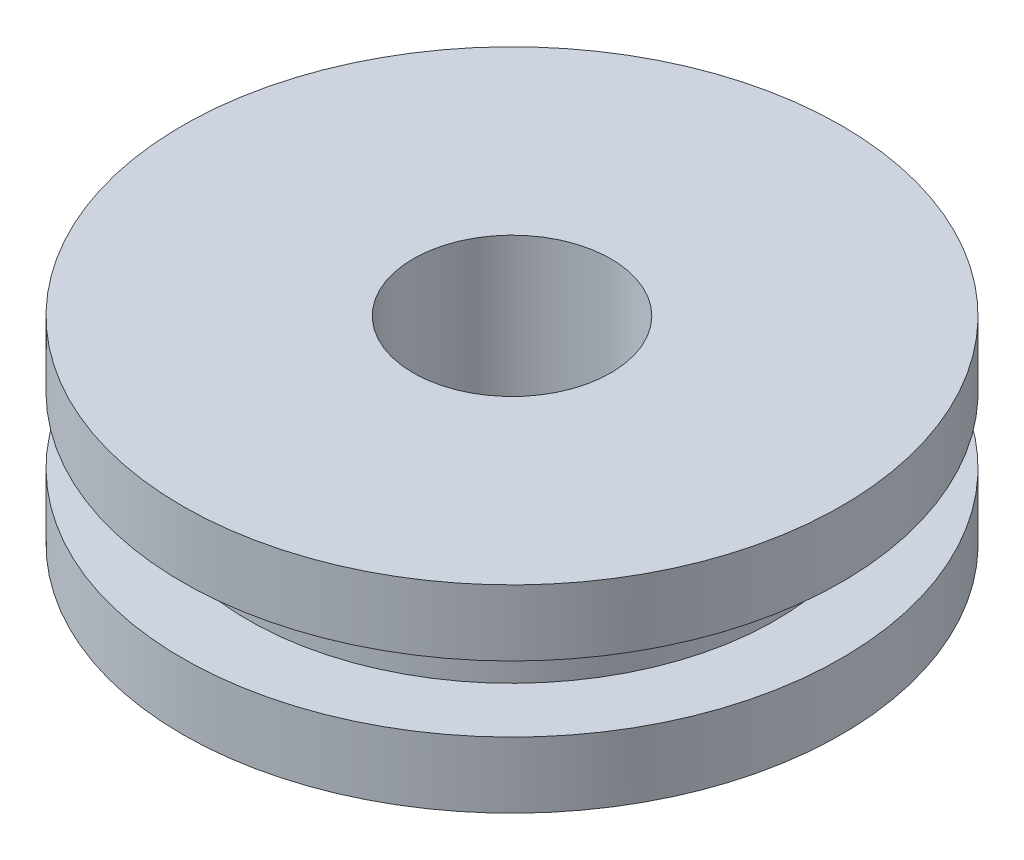
from build123d import *

# Parameters (mm, degrees)
SKETCH_1_R          = 5
EXTRUDE_1_DEPTH     = 3
SKETCH_2_R          = 1.5
CUT_EXTRUDE_1_DEPTH = 11
SKETCH_3_R          = 5
SKETCH_3_R_2        = 4
CUT_EXTRUDE_3_DEPTH = 0.5


with BuildPart() as part:
    # 草图1 → 凸台-拉伸1 (new body)
    with BuildSketch(Plane(origin=(0, 0, 0), x_dir=(1, 0, 0), z_dir=(0, 1, 0))):
        Circle(SKETCH_1_R)
    extrude(amount=EXTRUDE_1_DEPTH)

    # 草图2 → 切除-拉伸1 (cut)
    with BuildSketch(Plane(origin=(0, 3, 0), x_dir=(1, 0, 0), z_dir=(0, 1, 0))):
        Circle(SKETCH_2_R)
    extrude(amount=-CUT_EXTRUDE_1_DEPTH, mode=Mode.SUBTRACT)

    # 草图3 → 切除-拉伸3 (cut, symmetric)
    with BuildSketch(Plane(origin=(0, 1.5, 0), x_dir=(-1, 0, 0), z_dir=(0, -1, 0))):
        Circle(SKETCH_3_R)
        Circle(SKETCH_3_R_2, mode=Mode.SUBTRACT)
    extrude(amount=CUT_EXTRUDE_3_DEPTH, both=True, mode=Mode.SUBTRACT)


solid = part.part
